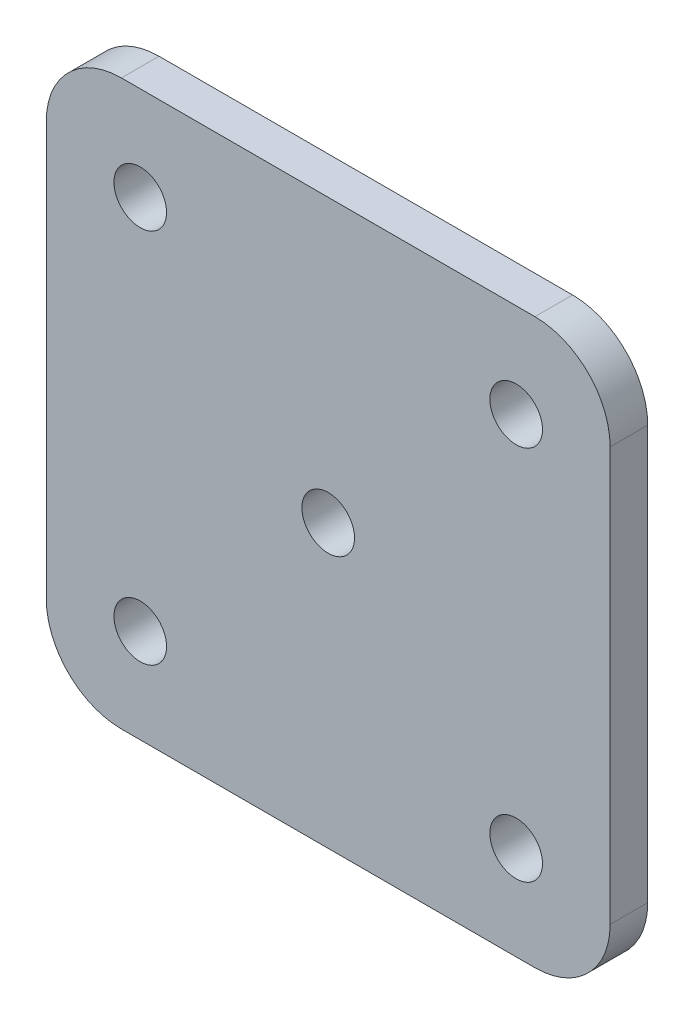
from build123d import *

# Parameters (mm, degrees)
SKETCH1_W                = 75
SKETCH1_H                = 75
BOSS_EXTRUDE1_DEPTH      = 5
F_7_0_7_DIAMETER_HOLE2_D = 7
FILLET1_R                = 10
F_7_0_7_DIAMETER_HOLE1_D = 7


with BuildPart() as part:
    # Sketch1 → Boss-Extrude1 (new body)
    with BuildSketch(Plane.XY):
        Rectangle(SKETCH1_W, SKETCH1_H)
    extrude(amount=BOSS_EXTRUDE1_DEPTH)

    # Ø7.0 (7) Diameter Hole2 (through all)
    with Locations(Plane.XY.offset(5)):
        with Locations((-25, 25), (-25, -25), (25, -25), (25, 25)):
            Hole(F_7_0_7_DIAMETER_HOLE2_D / 2)

    # Fillet1
    fillet1_edges = [part.edges().sort_by_distance(p)[0] for p in [
        (-37.5, 37.5, 2.5),
        (37.5, 37.5, 2.5),
        (37.5, -37.5, 2.5),
        (-37.5, -37.5, 2.5),
    ]]
    fillet(fillet1_edges, radius=FILLET1_R)

    # Ø7.0 (7) Diameter Hole1 (through all)
    with Locations(Plane.XY.offset(5)):
        with Locations((0, 0)):
            Hole(F_7_0_7_DIAMETER_HOLE1_D / 2)


solid = part.part
